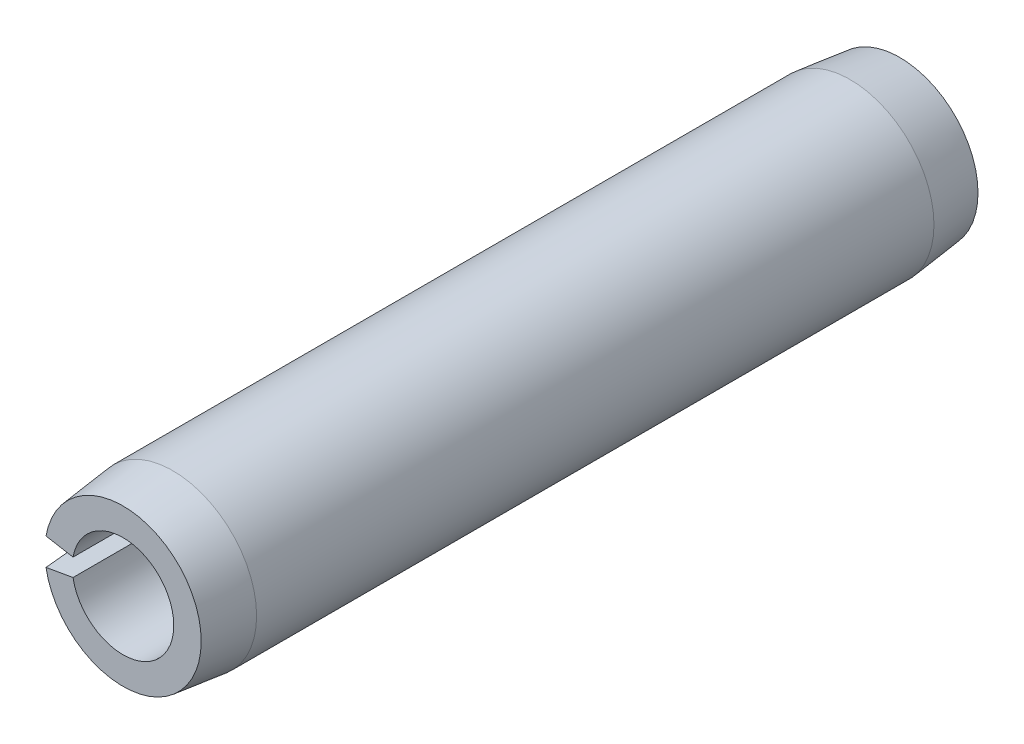
from build123d import *

# Parameters (mm, degrees)
EXTRUDE1_DEPTH = 9.525


with BuildPart() as part:
    # Sketch1 → Extrude1 (new body, symmetric)
    with BuildSketch(Plane.XY):
        with BuildLine():
            Line((-2.026143471, 0.357263761), (-1.225691729, 0.216122522))
            ThreePointArc((-1.225691729, 0.216122522), (1.2446, 0), (-1.225691729, -0.216122522))
            Line((-1.225691729, -0.216122522), (-2.026143471, -0.357263761))
            ThreePointArc((-2.026143471, -0.357263761), (2.0574, 0), (-2.026143471, 0.357263761))
        make_face()
    extrude(amount=EXTRUDE1_DEPTH, both=True)

    # Sketch2 → Cut-Revolve1 (revolve, cut)
    with BuildSketch(Plane(origin=(0, 0, 0), x_dir=(0, 0, -1), z_dir=(1, 0, 0))):
        Polygon((9.525, 2.0574), (9.525, 1.9177), (8.3058, 2.0574), align=None)
        Polygon((-8.3058, 2.0574), (-9.525, 2.0574), (-9.525, 1.9177), align=None)
    revolve(axis=Axis((0, 0, -9.525), (0, 0, 1)), mode=Mode.SUBTRACT)


solid = part.part
